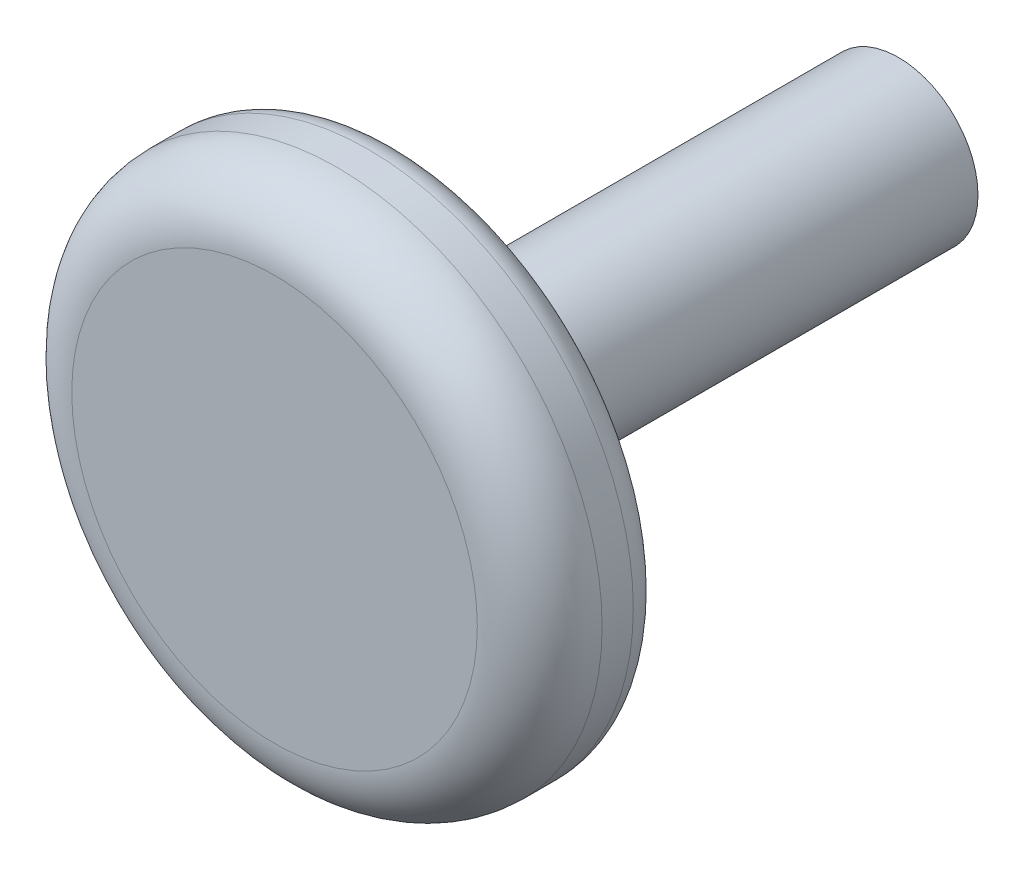
from build123d import *

# Parameters (mm, degrees)
CROQUIS1_R              = 12.75
SALIENTE_EXTRUIR1_DEPTH = 80
CROQUIS2_R              = 42.5
SALIENTE_EXTRUIR2_DEPTH = 20
REDONDEO1_R             = 10
CROQUIS3_R              = 10.25
CORTAR_EXTRUIR1_DEPTH   = 10
REDONDEO2_R             = 10
REDONDEO3_R             = 5


with BuildPart() as part:
    # Croquis1 → Saliente-Extruir1 (new body)
    with BuildSketch(Plane.XY):
        Circle(CROQUIS1_R)
    extrude(amount=SALIENTE_EXTRUIR1_DEPTH)

    # Croquis2 → Saliente-Extruir2 (add)
    with BuildSketch(Plane.XY.offset(80)):
        Circle(CROQUIS2_R)
    extrude(amount=SALIENTE_EXTRUIR2_DEPTH)

    # Redondeo1
    redondeo1_edges = [part.edges().sort_by_distance(p)[0] for p in [
        (-42.5, 0, 100),
    ]]
    fillet(redondeo1_edges, radius=REDONDEO1_R)

    # Croquis3 → Cortar-Extruir1 (cut)
    with BuildSketch(Plane(origin=(0, 0, 0), x_dir=(-1, 0, 0), z_dir=(0, 0, -1))):
        Circle(CROQUIS3_R)
    extrude(amount=-CORTAR_EXTRUIR1_DEPTH, mode=Mode.SUBTRACT)

    # Redondeo2
    redondeo2_edges = [part.edges().sort_by_distance(p)[0] for p in [
        (-12.75, 0, 80),
    ]]
    fillet(redondeo2_edges, radius=REDONDEO2_R)

    # Redondeo3
    redondeo3_edges = [part.edges().sort_by_distance(p)[0] for p in [
        (-42.5, 0, 80),
    ]]
    fillet(redondeo3_edges, radius=REDONDEO3_R)


solid = part.part
